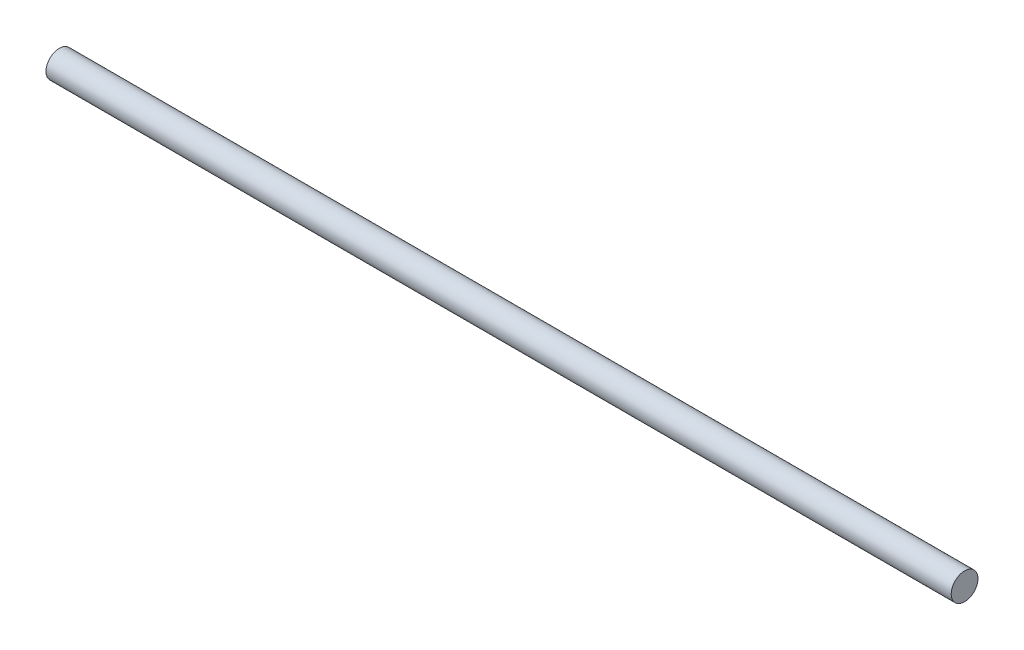
from build123d import *

# Parameters (mm, degrees)
SKETCH1_R           = 14.2875
BOSS_EXTRUDE1_DEPTH = 482.6


with BuildPart() as part:
    # Sketch1 → Boss-Extrude1 (new body, symmetric)
    with BuildSketch(Plane(origin=(0, 0, 0), x_dir=(0, 0, -1), z_dir=(1, 0, 0))):
        Circle(SKETCH1_R)
    extrude(amount=BOSS_EXTRUDE1_DEPTH, both=True)


solid = part.part
